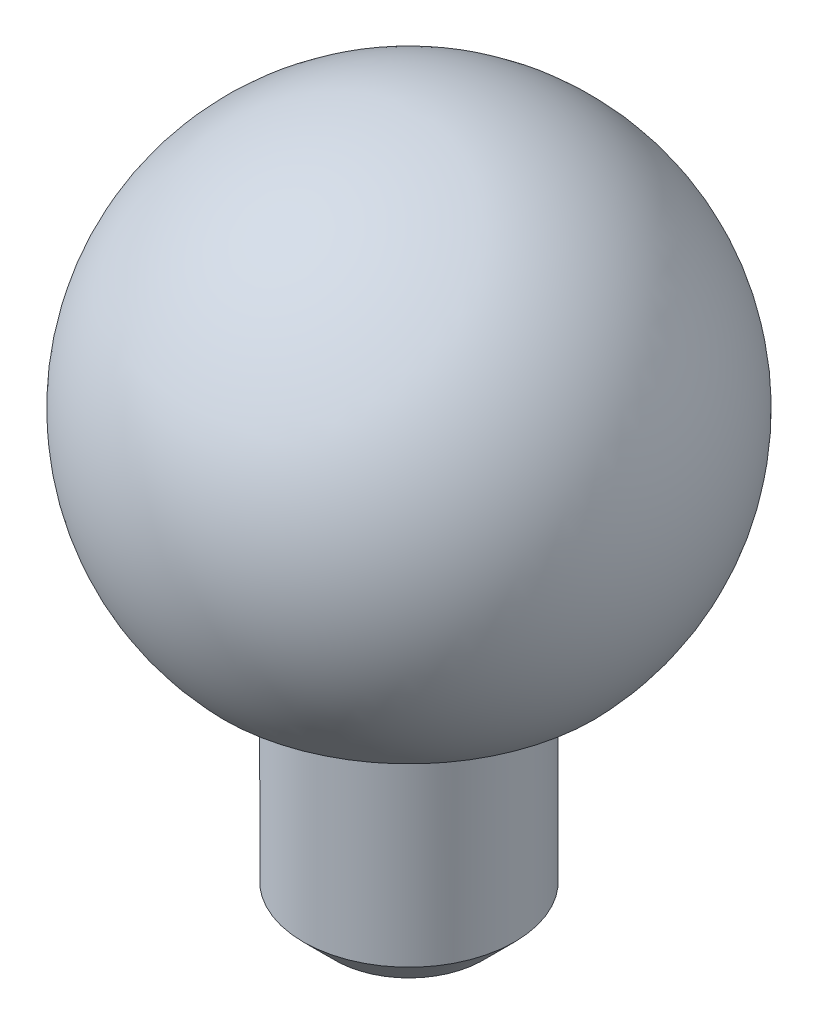
from build123d import *

# Parameters (mm, degrees)
SKIZZE2_R                       = 2
AUFSATZ_LINEAR_AUSTRAGEN1_DEPTH = 5
FASE1_SIZE                      = 0.6


with BuildPart() as part:
    # Skizze1 → Rotation1 (revolve)
    with BuildSketch(Plane(origin=(0, 0, 0), x_dir=(0, 0, -1), z_dir=(1, 0, 0))):
        with BuildLine():
            ThreePointArc((3.507135583, -3.35), (4.459260028, 1.907223112), (0, 4.85))
            Line((0, 4.85), (0, -3.35))
            Line((0, -3.35), (3.507135583, -3.35))
        make_face()
    revolve(axis=Axis((0, 21.112600536, 0), (0, -1, 0)))

    # Skizze2 → Aufsatz-Linear austragen1 (add)
    with BuildSketch(Plane.XZ.offset(3.35)):
        Circle(SKIZZE2_R)
    extrude(amount=AUFSATZ_LINEAR_AUSTRAGEN1_DEPTH)

    # Fase1
    fase1_edges = [part.edges().sort_by_distance(p)[0] for p in [
        (-2, -8.35, 0),
    ]]
    chamfer(fase1_edges, length=FASE1_SIZE)


solid = part.part
